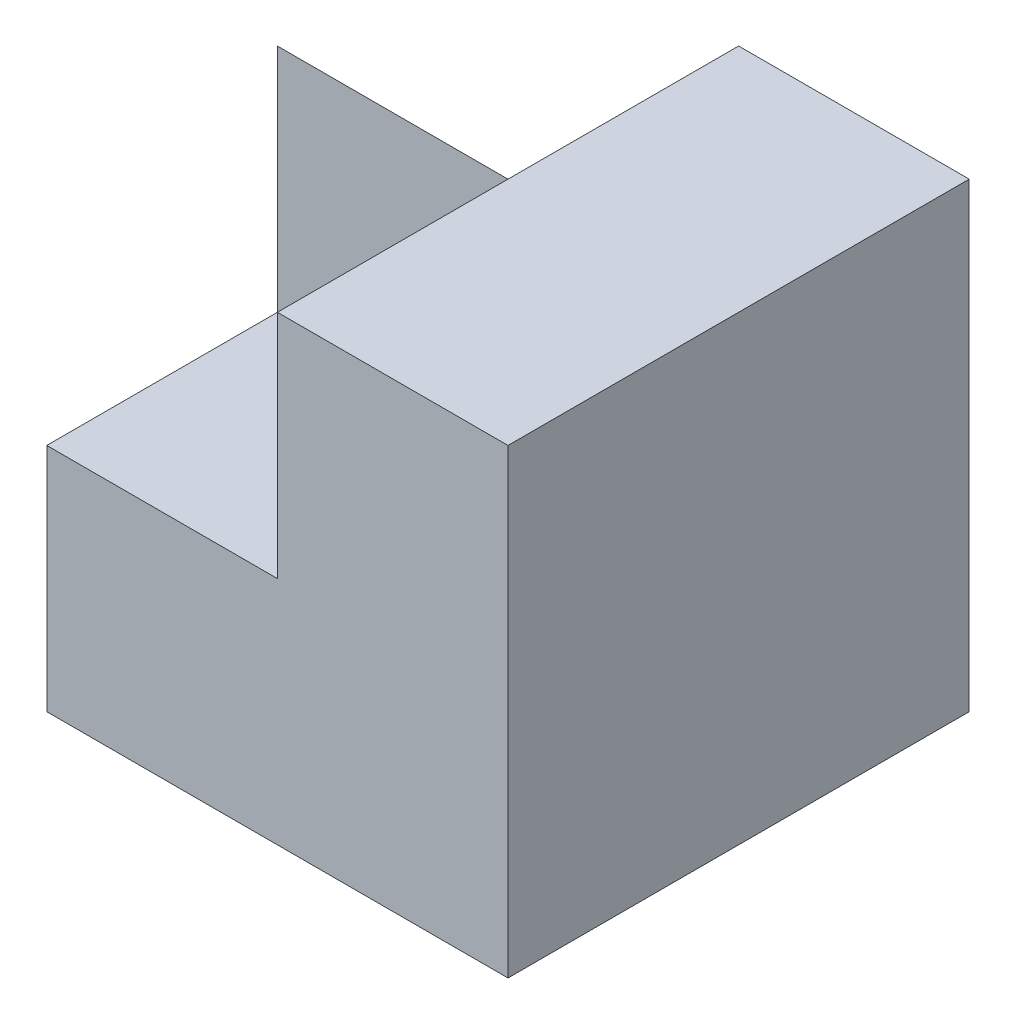
from build123d import *

# Parameters (mm, degrees)
SKETCH1_W           = 4
SKETCH1_H           = 4
BOSS_EXTRUDE1_DEPTH = 4
SKETCH2_W           = 2
SKETCH2_H           = 2
CUT_EXTRUDE1_DEPTH  = 2


with BuildPart() as part:
    # Sketch1 → Boss-Extrude1 (new body)
    with BuildSketch(Plane(origin=(0, 0, 0), x_dir=(1, 0, 0), z_dir=(0, 1, 0))):
        Rectangle(SKETCH1_W, SKETCH1_H)
    extrude(amount=BOSS_EXTRUDE1_DEPTH)

    # Sketch2 → Cut-Extrude1 (cut)
    with BuildSketch(Plane.ZY.offset(2)):
        Polygon((-2, 4), (-2, 2), (0, 4), align=None)
        with Locations((1, 3)):
            Rectangle(SKETCH2_W, SKETCH2_H)
    extrude(amount=-CUT_EXTRUDE1_DEPTH, mode=Mode.SUBTRACT)


solid = part.part
